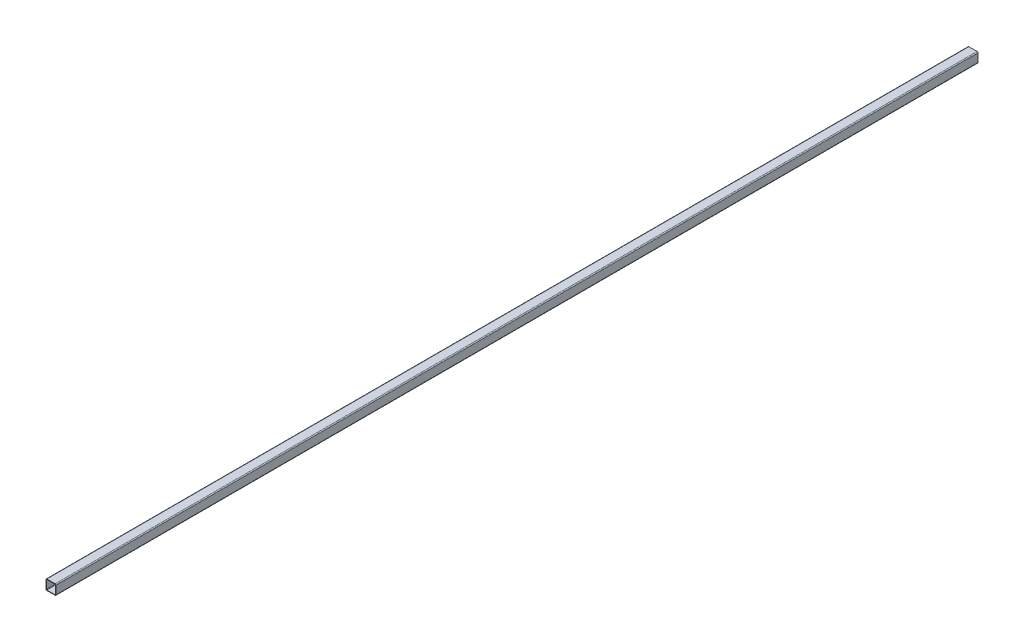
from build123d import *

# Parameters (mm, degrees)
BOSS_EXTRUDE1_DEPTH = 1270


with BuildPart() as part:
    # Sketch1 → Boss-Extrude1 (new body, symmetric)
    with BuildSketch(Plane.XY):
        with BuildLine():
            Line((-11.2903, 13.8303), (11.2903, 13.8303))
            ThreePointArc((11.2903, 13.8303), (13.086351224, 13.086351224), (13.8303, 11.2903))
            Line((13.8303, 11.2903), (13.8303, -11.2903))
            ThreePointArc((13.8303, -11.2903), (13.086351224, -13.086351224), (11.2903, -13.8303))
            Line((11.2903, -13.8303), (-11.2903, -13.8303))
            ThreePointArc((-11.2903, -13.8303), (-13.086351224, -13.086351224), (-13.8303, -11.2903))
            Line((-13.8303, -11.2903), (-13.8303, 11.2903))
            ThreePointArc((-13.8303, 11.2903), (-13.086351224, 13.086351224), (-11.2903, 13.8303))
        make_face()
        with BuildLine():
            Line((-12.5603, 11.2903), (-12.5603, -11.2903))
            ThreePointArc((-12.5603, -11.2903), (-12.188325612, -12.188325612), (-11.2903, -12.5603))
            Line((-11.2903, -12.5603), (11.2903, -12.5603))
            ThreePointArc((11.2903, -12.5603), (12.188325612, -12.188325612), (12.5603, -11.2903))
            Line((12.5603, -11.2903), (12.5603, 11.2903))
            ThreePointArc((12.5603, 11.2903), (12.188325612, 12.188325612), (11.2903, 12.5603))
            Line((11.2903, 12.5603), (-11.2903, 12.5603))
            ThreePointArc((-11.2903, 12.5603), (-12.188325612, 12.188325612), (-12.5603, 11.2903))
        make_face(mode=Mode.SUBTRACT)
    extrude(amount=BOSS_EXTRUDE1_DEPTH, both=True)


solid = part.part
